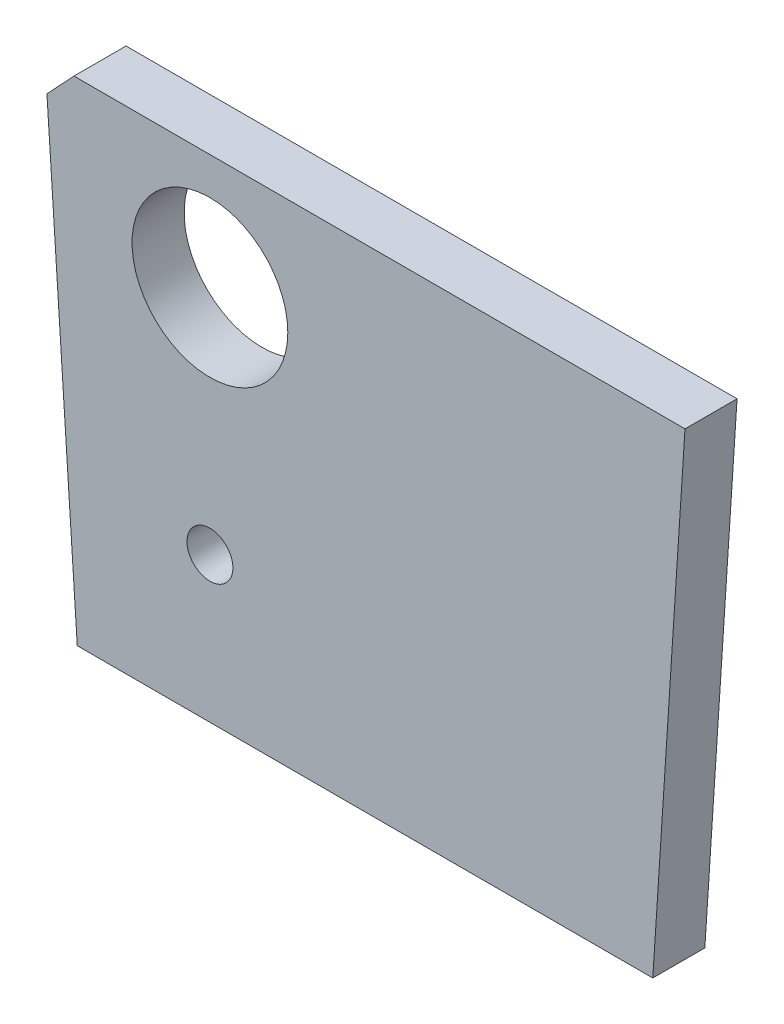
from build123d import *

# Parameters (mm, degrees)
SKETCH1_R             = 0.396875
SKETCH1_R_2           = 1.3462
EXTRUDE1_DEPTH        = 0.9
CHAMFER1_SIZE         = 1.3
CHAMFER1_SIZE2        = 1.136906158
CHAMFER1_EDGE_2_SIZE  = 1.3
CHAMFER1_EDGE_2_SIZE2 = 1.136906158
SKETCH2_R             = 0.396875
SKETCH2_R_2           = 1.3462
EXTRUDE2_DEPTH        = 0.9
CUT_EXTRUDE2_DEPTH    = 1.9
CHAMFER2_SIZE         = 0.5


with BuildPart() as part:
    # Sketch1 → Extrude1 (new body)
    with BuildSketch(Plane.XY):
        Polygon((-2.158886106, 43.490401799), (2.158886106, 43.490401799), (0.81962306, 34.990401799), (-0.81962306, 34.990401799), align=None)
        with Locations((0, 37.5)):
            Circle(SKETCH1_R, mode=Mode.SUBTRACT)
        with Locations((0, 41.5)):
            Circle(SKETCH1_R_2, mode=Mode.SUBTRACT)
    extrude(amount=EXTRUDE1_DEPTH)

    # Chamfer1
    chamfer1_edges = [part.edges().sort_by_distance(p)[0] for p in [
        (-2.158886106, 43.490401799, 0.45),
    ]]
    chamfer1_side = [part.faces().sort_by_distance(p)[0] for p in [
        (0, 43.490401799, 0.45),
    ]]
    chamfer(chamfer1_edges, length=CHAMFER1_SIZE, length2=CHAMFER1_SIZE2, reference=chamfer1_side[0])

    # Chamfer1 edge 2
    chamfer1_edge_2_edges = [part.edges().sort_by_distance(p)[0] for p in [
        (2.158886106, 43.490401799, 0.45),
    ]]
    chamfer1_edge_2_side = [part.faces().sort_by_distance(p)[0] for p in [
        (0, 43.490401799, 0.45),
    ]]
    chamfer(chamfer1_edge_2_edges, length=CHAMFER1_EDGE_2_SIZE, length2=CHAMFER1_EDGE_2_SIZE2, reference=chamfer1_edge_2_side[0])

    # Sketch2 → Extrude2 (add)
    with BuildSketch(Plane(origin=(0, 0, 0.9), x_dir=(-1, 0, 0), z_dir=(0, 0, -1))):
        Polygon((-8.212619969, 43.490401799), (8.212619969, 43.490401799), (7.655500535, 34.990401799), (-7.655500535, 34.990401799), align=None)
        with Locations(Location((0, 37.5, 0), (0, 0, 180))):  # turned: the seam where the file's is
            Circle(SKETCH2_R, mode=Mode.SUBTRACT)
        with Locations(Location((0, 41.5, 0), (0, 0, 180))):  # turned: the seam where the file's is
            Circle(SKETCH2_R_2, mode=Mode.SUBTRACT)
    extrude(amount=EXTRUDE2_DEPTH)

    # Sketch4 → Cut-Extrude2 (cut, through all)
    with BuildSketch(Plane(origin=(0, 0, 0), x_dir=(-1, 0, 0), z_dir=(0, 0, -1))):
        Polygon((2.293392099, 34.990401799), (2.850511533, 43.490401799), (8.212619969, 43.490401799), (7.655500535, 34.990401799), align=None)
    extrude(amount=-CUT_EXTRUDE2_DEPTH, mode=Mode.SUBTRACT)

    # Chamfer2
    chamfer2_edges = [part.edges().sort_by_distance(p)[0] for p in [
        (-2.850511533, 43.490401799, 0.45),
    ]]
    chamfer(chamfer2_edges, length=CHAMFER2_SIZE)


solid = part.part
